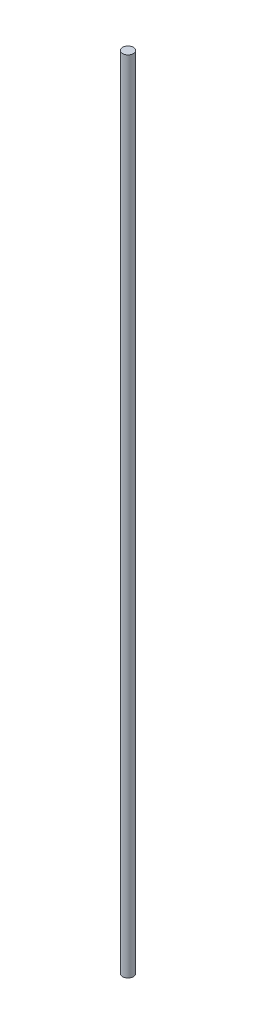
from build123d import *

# Parameters (mm, degrees)
SKETCH1_R           = 1
BOSS_EXTRUDE1_DEPTH = 73.5


with BuildPart() as part:
    # Sketch1 → Boss-Extrude1 (new body, symmetric)
    with BuildSketch(Plane(origin=(0, 0, 0), x_dir=(1, 0, 0), z_dir=(0, 1, 0))):
        Circle(SKETCH1_R)
    extrude(amount=BOSS_EXTRUDE1_DEPTH, both=True)


solid = part.part
